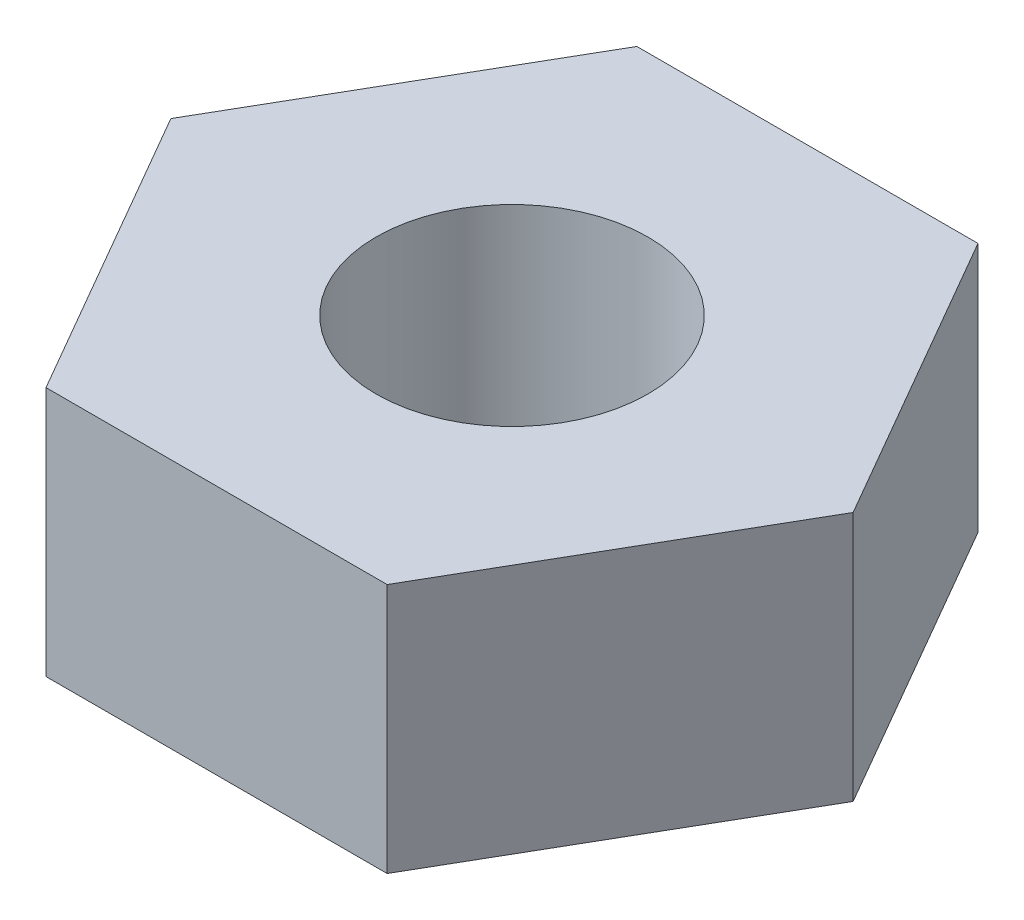
from build123d import *

# Parameters (mm, degrees)
SKETCH1_R           = 1.25
BOSS_EXTRUDE1_DEPTH = 2.3


with BuildPart() as part:
    # Sketch1 → Boss-Extrude1 (new body)
    with BuildSketch(Plane(origin=(0, 0, 0), x_dir=(1, 0, 0), z_dir=(0, 1, 0))):
        Polygon((3.135011962, 0), (1.567505981, 2.715), (-1.567505981, 2.715), (-3.135011962, 0), (-1.567505981, -2.715), (1.567505981, -2.715), align=None)
        Circle(SKETCH1_R, mode=Mode.SUBTRACT)
    extrude(amount=BOSS_EXTRUDE1_DEPTH)


solid = part.part
